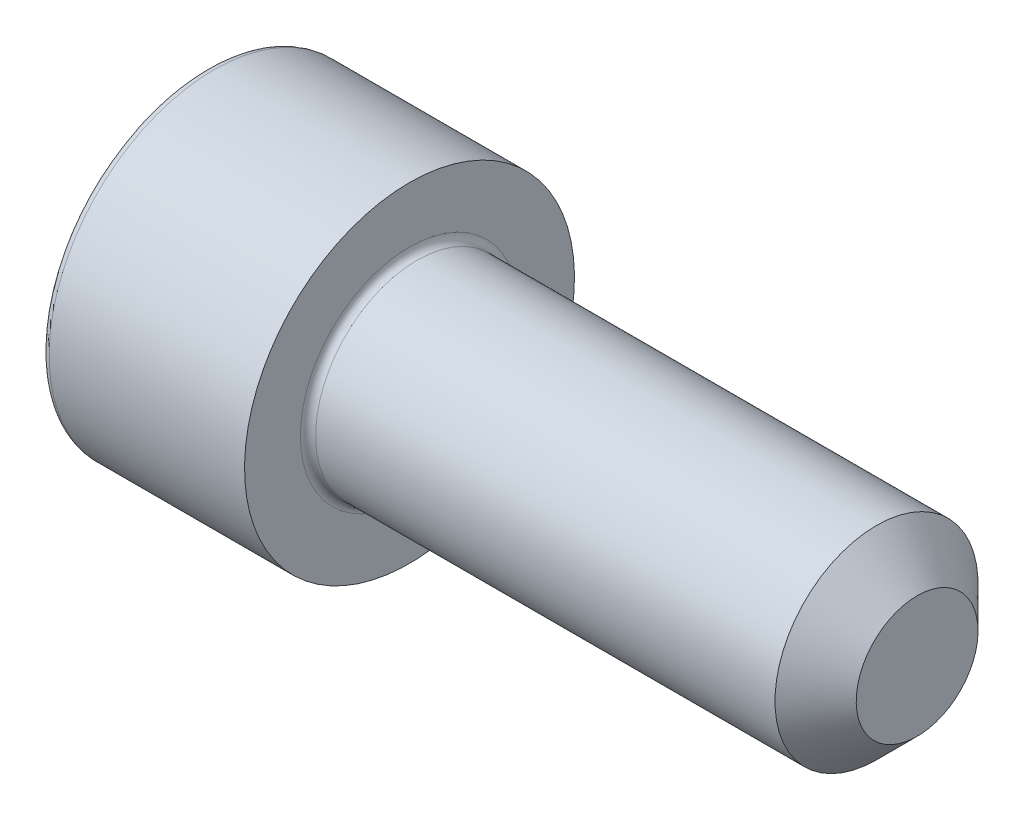
from build123d import *

# Parameters (mm, degrees)
CUT_EXTRUDE_1_DEPTH = 2.5
FILLET_1_R          = 0.3
CHAMFER_1_SIZE      = 1.6


with BuildPart() as part:
    # Эскиз1 → Повернуть1 (revolve)
    with BuildSketch(Plane.XY):
        Polygon((0, 0), (0, 6.5), (8, 6.5), (8, 4), (28, 4), (28, 0), align=None)
    revolve(axis=Axis((28, 0, 0), (-1, 0, 0)))

    # Эскиз2 → Вырез-Вытянуть1 (cut)
    with BuildSketch(Plane.ZY):
        Polygon((-1.732050808, 3), (-3.464101615, 0), (-1.732050808, -3), (1.732050808, -3), (3.464101615, 0), (1.732050808, 3), align=None)
    extrude(amount=-CUT_EXTRUDE_1_DEPTH, mode=Mode.SUBTRACT)

    # Скругление1
    fillet_1_edges = [part.edges().sort_by_distance(p)[0] for p in [
        (8, -4, 0),
        (0, -6.5, 0),
    ]]
    fillet(fillet_1_edges, radius=FILLET_1_R)

    # Фаска1
    chamfer_1_edges = [part.edges().sort_by_distance(p)[0] for p in [
        (28, -4, 0),
    ]]
    chamfer(chamfer_1_edges, length=CHAMFER_1_SIZE)


solid = part.part
